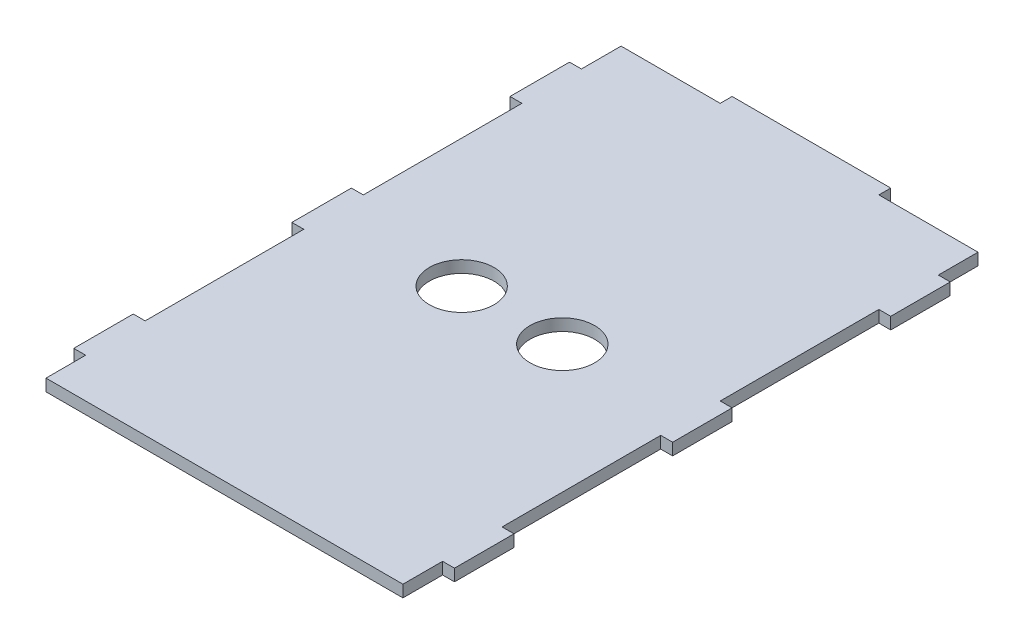
from build123d import *

# Parameters (mm, degrees)
SKETCH1_W           = 90
SKETCH1_H           = 132
BOSS_EXTRUDE1_DEPTH = 3
SKETCH7_W           = 90
SKETCH7_H           = 13
BOSS_EXTRUDE7_DEPTH = 3
SKETCH5_W           = 3
SKETCH5_H           = 15
BOSS_EXTRUDE5_DEPTH = 3
SKETCH6_W           = 40
SKETCH6_H           = 3
BOSS_EXTRUDE6_DEPTH = 3
SKETCH8_R           = 8.15
CUT_EXTRUDE1_DEPTH  = 3


with BuildPart() as part:
    # Sketch1 → Boss-Extrude1 (new body)
    with BuildSketch(Plane(origin=(0, 0, 0), x_dir=(1, 0, 0), z_dir=(0, 1, 0))):
        with Locations((45, 66)):
            Rectangle(SKETCH1_W, SKETCH1_H)
    extrude(amount=BOSS_EXTRUDE1_DEPTH)

    # Sketch7 → Boss-Extrude7 (add)
    with BuildSketch(Plane(origin=(0, 3, 0), x_dir=(1, 0, 0), z_dir=(0, 1, 0))):
        with Locations((45, 138.5)):
            Rectangle(SKETCH7_W, SKETCH7_H)
    extrude(amount=-BOSS_EXTRUDE7_DEPTH)

    # Sketch5 → Boss-Extrude5 (add)
    with BuildSketch(Plane(origin=(0, 3, 0), x_dir=(1, 0, 0), z_dir=(0, 1, 0))):
        with Locations((-1.5, 127.5)):
            Rectangle(SKETCH5_W, SKETCH5_H)
        with Locations((-1.5, 72.5)):
            Rectangle(SKETCH5_W, SKETCH5_H)
        with Locations((-1.5, 17.5)):
            Rectangle(SKETCH5_W, SKETCH5_H)
        with Locations((91.5, 127.5)):
            Rectangle(SKETCH5_W, SKETCH5_H)
        with Locations((91.5, 72.5)):
            Rectangle(SKETCH5_W, SKETCH5_H)
        with Locations((91.5, 17.5)):
            Rectangle(SKETCH5_W, SKETCH5_H)
    extrude(amount=-BOSS_EXTRUDE5_DEPTH)

    # Sketch6 → Boss-Extrude6 (add)
    with BuildSketch(Plane(origin=(0, 3, 0), x_dir=(1, 0, 0), z_dir=(0, 1, 0))):
        with Locations((45, 146.5)):
            Rectangle(SKETCH6_W, SKETCH6_H)
    extrude(amount=-BOSS_EXTRUDE6_DEPTH)

    # Sketch8 → Cut-Extrude1 (cut)
    with BuildSketch(Plane(origin=(0, 3, 0), x_dir=(1, 0, 0), z_dir=(0, 1, 0))):
        with Locations((32.31, 72.5)):
            Circle(SKETCH8_R)
        with Locations((57.69, 72.5)):
            Circle(SKETCH8_R)
    extrude(amount=-CUT_EXTRUDE1_DEPTH, mode=Mode.SUBTRACT)


solid = part.part
